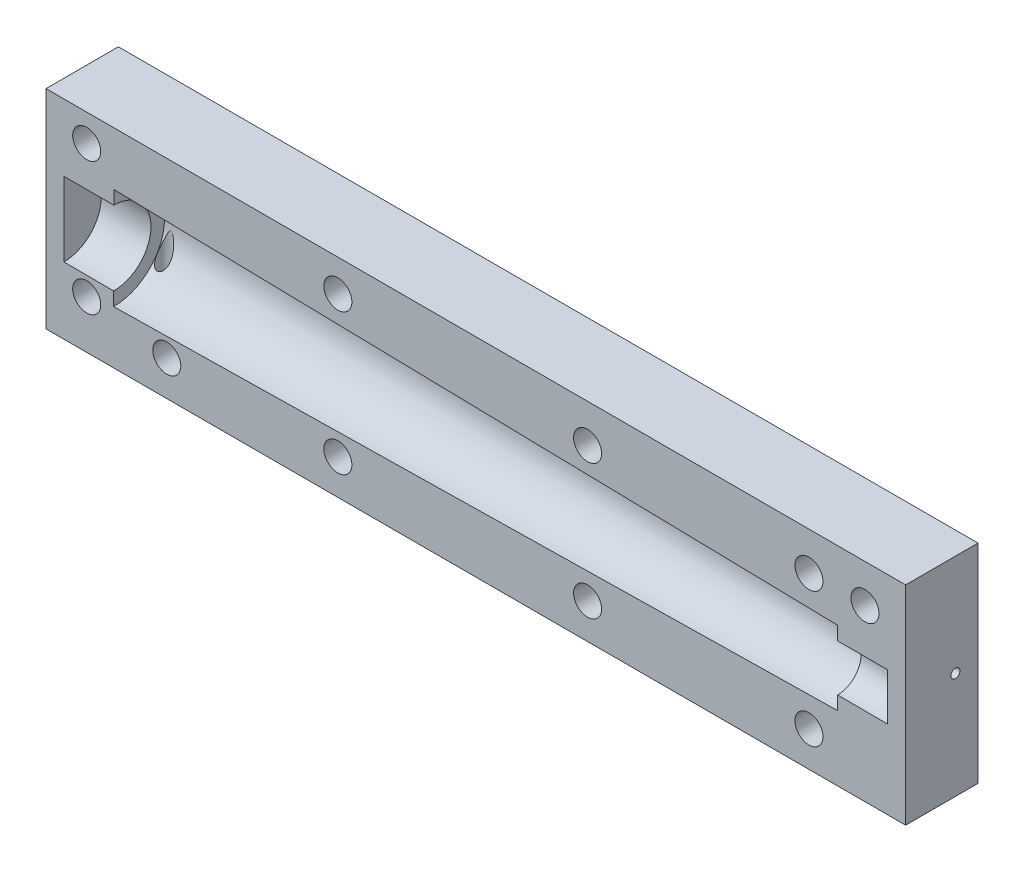
from build123d import *

# Parameters (mm, degrees)
SKIZZE2_W                                  = 120
SKIZZE2_H                                  = 40
AUFSATZ_LINEAR_AUSTRAGEN1_DEPTH            = 30
SKIZZE80_R                                 = 0.5
SCHNITT_LINEAR_AUSTRAGEN34_DEPTH           = 21.05
SCHNITT_LINEAR_START                       = -9
SKIZZE81_R                                 = 0.5
SCHNITT_LINEAR_AUSTRAGEN36_DEPTH           = 5
SKIZZE89_R                                 = 0.75
SCHNITT_LINEAR_AUSTRAGEN37_DEPTH           = 19
SKIZZE89_3_R                               = 2.1
SKIZZE89_3_R_2                             = 0.75
SCHNITT_LINEAR_AUSTRAGEN38_DEPTH           = 12
FASE1_SIZE                                 = 1.3
F_3_1_3_1_DURCHMESSER_BOHRUNG1_D           = 3.1
F_3_1_3_1_DURCHMESSER_BOHRUNG1_CSINK_D     = 3.15
F_3_1_3_1_DURCHMESSER_BOHRUNG1_CSINK_ANGLE = 90
SKIZZE83_W                                 = 8.5
SKIZZE83_H                                 = 23
SKIZZE83_W_2                               = 7
SCHNITT_LINEAR_AUSTRAGEN39_DEPTH           = 135
SKIZZE93_W                                 = 12.5
SKIZZE93_H                                 = 14.5
SCHNITT_LINEAR_AUSTRAGEN40_DEPTH           = 135
ABSPALTEN1_SURFACE_1_BACK                  = 99.814
ABSPALTEN1_SURFACE_1_DEPTH                 = 199.628


with BuildPart() as part:
    # Skizze2 → Aufsatz-Linear austragen1 (new body)
    with BuildSketch(Plane.XY):
        with Locations((60, 20)):
            Rectangle(SKIZZE2_W, SKIZZE2_H)
    extrude(amount=AUFSATZ_LINEAR_AUSTRAGEN1_DEPTH)

    # Skizze80 → Schnitt-Linear austragen34 (cut)
    with BuildSketch(Plane(origin=(120, 0, 0), x_dir=(0, 0, -1), z_dir=(1, 0, 0))):
        with Locations((-20.502569313, 19.779069372)):
            Circle(SKIZZE80_R)
    schnitt_linear_austragen34 = extrude(amount=-SCHNITT_LINEAR_AUSTRAGEN34_DEPTH, mode=Mode.SUBTRACT)

    # Skizze81 → Schnitt-Linear austragen36 (cut)
    with BuildSketch(Plane.XY.offset(30).offset(SCHNITT_LINEAR_START)):
        with Locations((99, 20)):
            Circle(SKIZZE81_R)
    schnitt_linear_austragen36 = extrude(amount=-SCHNITT_LINEAR_AUSTRAGEN36_DEPTH, mode=Mode.SUBTRACT)

    # Spiegeln4: Schnitt-Linear austragen34, Schnitt-Linear austragen36 across plane
    add(schnitt_linear_austragen34.mirror(Plane.XY.offset(15)), mode=Mode.SUBTRACT)
    add(schnitt_linear_austragen36.mirror(Plane.XY.offset(15)), mode=Mode.SUBTRACT)

    # Skizze89 → Schnitt-Linear austragen37 (cut)
    with BuildSketch(Plane.XZ):
        with Locations(Location((20.75, 10.195, 0), (0, 0, 270))):
            Circle(SKIZZE89_R)
    extrude(amount=-SCHNITT_LINEAR_AUSTRAGEN37_DEPTH, mode=Mode.SUBTRACT)

    # Skizze89_3 → Schnitt-Linear austragen38 (cut)
    with BuildSketch(Plane.XZ):
        with Locations(Location((20.75, 10.195, 0), (0, 0, 270))):
            Circle(SKIZZE89_3_R)
        with Locations(Location((20.75, 10.195, 0), (0, 0, 270))):
            Circle(SKIZZE89_3_R_2, mode=Mode.SUBTRACT)
    extrude(amount=-SCHNITT_LINEAR_AUSTRAGEN38_DEPTH, mode=Mode.SUBTRACT)

    # Fase1
    fase1_edges = [part.edges().sort_by_distance(p)[0] for p in [
        (20.75, 12, 10.945),
    ]]
    chamfer(fase1_edges, length=FASE1_SIZE)

    # 3.1 _3.1_ Durchmesser Bohrung1 (through all)
    with Locations(Plane(origin=(0, 0, 0), x_dir=(-1, 0, 0), z_dir=(0, 0, -1))):
        with Locations((-17, 28), (-44.752782077, 27.472603229), (-72.354196867, 26.76756786), (-96.819713549, 26.76756786), (-103.008357344, 26.76756786), (-17, 13.319343937), (-25.846153065, 11.883487847), (-44.752782077, 11.883487847), (-72.354196867, 11.883487847), (-96.819713549, 11.883487847)):
            CounterSinkHole(F_3_1_3_1_DURCHMESSER_BOHRUNG1_D / 2, F_3_1_3_1_DURCHMESSER_BOHRUNG1_CSINK_D / 2, counter_sink_angle=F_3_1_3_1_DURCHMESSER_BOHRUNG1_CSINK_ANGLE)

    # Skizze83 → Schnitt-Linear austragen39 (cut)
    with BuildSketch(Plane.ZY):
        with Locations((25.75, 19.5)):
            Rectangle(SKIZZE83_W, SKIZZE83_H)
        Polygon((30, 0), (30, 8), (21.5, 8), (7, 8), (0, 8), (0, 0), align=None)
        with Locations((3.5, 19.5)):
            Rectangle(SKIZZE83_W_2, SKIZZE83_H)
        Polygon((21.5, 31), (30, 31), (30, 40), (0, 40), (0, 31), (7, 31), align=None)
    extrude(amount=-SCHNITT_LINEAR_AUSTRAGEN39_DEPTH, mode=Mode.SUBTRACT)

    # Skizze93 → Schnitt-Linear austragen40 (cut)
    with BuildSketch(Plane(origin=(0, 31, 0), x_dir=(1, 0, 0), z_dir=(0, 1, 0))):
        with Locations((113.75, -14.25)):
            Rectangle(SKIZZE93_W, SKIZZE93_H)
        with Locations((6.25, -14.25)):
            Rectangle(SKIZZE93_W, SKIZZE93_H)
    extrude(amount=-SCHNITT_LINEAR_AUSTRAGEN40_DEPTH, mode=Mode.SUBTRACT)

    # Skizze99 → Schnitt-Rotation2 (revolve, cut)
    with BuildSketch(Plane.XY.offset(15), mode=Mode.PRIVATE) as schnitt_rotation2_sk:
        Polygon((14.5, 19.495348829), (14.5, 23.595348829), (20, 23.595348829), (20, 25.095348829), (100, 23.383720543), (100, 21.883720543), (105.5, 21.883720543), (105.5, 19.283720543), align=None)
    revolve(schnitt_rotation2_sk.sketch.rotate(Axis((12.5, 19.5, 15), (0.9999972958368729, -0.0023255792701378343, 0)), 180), axis=Axis((12.5, 19.5, 15), (0.9999972958368729, -0.0023255792701378343, 0)), mode=Mode.SUBTRACT)

    # Abspalten1: cut with a surface, the side it looks to stays
    # Abspalten1 surface: a surface, the sketch's curves swept straight by 199.628 mm
    with BuildLine(Plane(origin=(107.5, 0, 0), x_dir=(0, 0, -1), z_dir=(1, 0, 0)).offset(-ABSPALTEN1_SURFACE_1_BACK), mode=Mode.PRIVATE) as abspalten1_surface_1_path:
        Line((-15, 31), (-15, 8))
    abspalten1_surface_1 = Shell.extrude(abspalten1_surface_1_path.wire(), (1 * ABSPALTEN1_SURFACE_1_DEPTH, 0 * ABSPALTEN1_SURFACE_1_DEPTH, 0 * ABSPALTEN1_SURFACE_1_DEPTH))
    split(bisect_by=abspalten1_surface_1, keep=Keep.TOP)


solid = part.part
